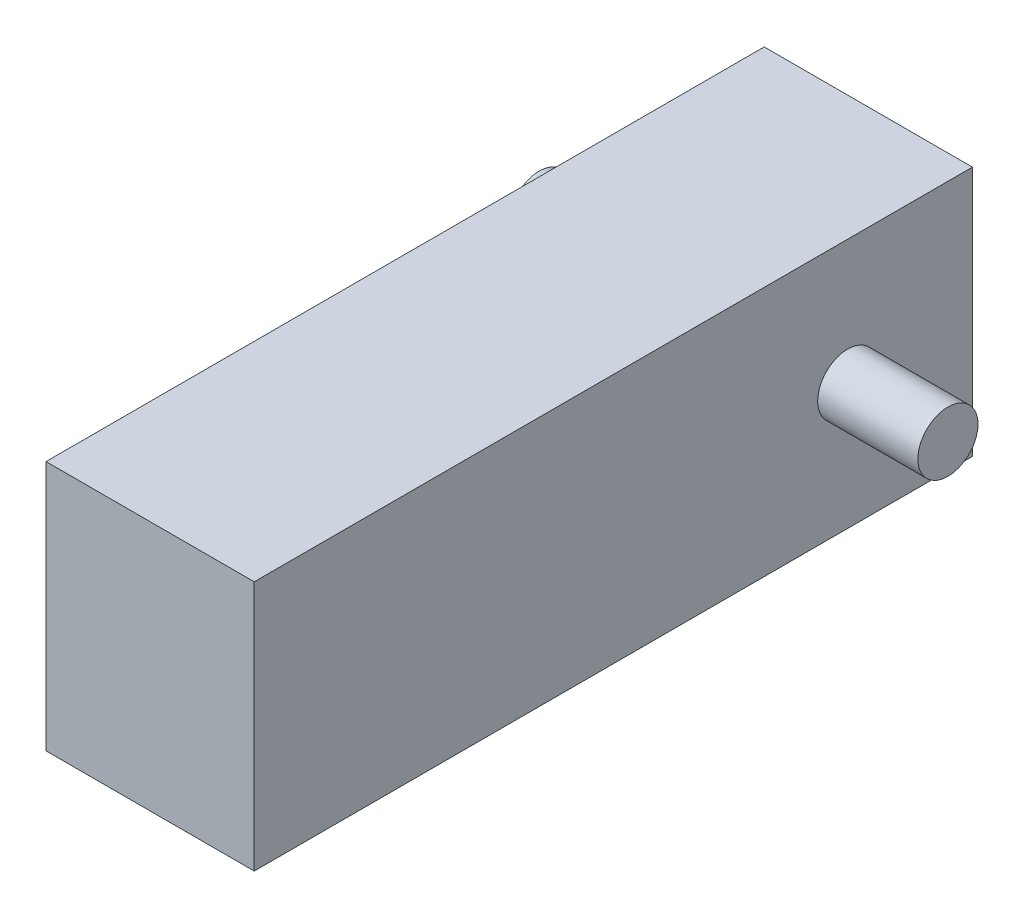
from build123d import *

# Parameters (mm, degrees)
SKETCH1_W           = 18.7
SKETCH1_H           = 64.5
BOSS_EXTRUDE1_DEPTH = 22.5
SKETCH2_R           = 2.7
BOSS_EXTRUDE2_DEPTH = 9


with BuildPart() as part:
    # Sketch1 → Boss-Extrude1 (new body)
    with BuildSketch(Plane(origin=(0, 0, 0), x_dir=(1, 0, 0), z_dir=(0, 1, 0))):
        Rectangle(SKETCH1_W, SKETCH1_H)
    extrude(amount=BOSS_EXTRUDE1_DEPTH)

    # Sketch2 → Boss-Extrude2 (add)
    with BuildSketch(Plane(origin=(9.35, 0, 0), x_dir=(0, 0, -1), z_dir=(1, 0, 0))):
        with Locations((21.05, 11.25)):
            Circle(SKETCH2_R)
    boss_extrude2 = extrude(amount=BOSS_EXTRUDE2_DEPTH)

    # Mirror1: Boss-Extrude2 across plane
    add(boss_extrude2.mirror(Plane(origin=(0, 0, 0), x_dir=(0, 0, 1), z_dir=(1, 0, 0))))


solid = part.part
